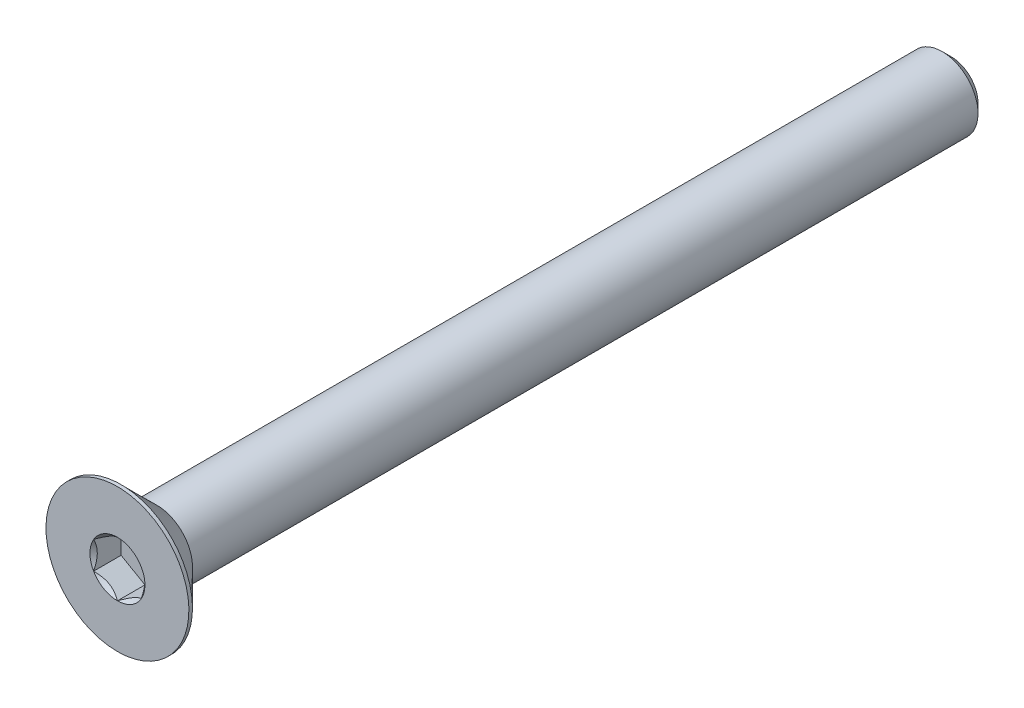
from build123d import *

# Parameters (mm, degrees)
SKETCH1_W          = 70
SKETCH1_H          = 3
CHAMFER1_SIZE      = 0.75
CUT_EXTRUDE2_DEPTH = 2.31


with BuildPart() as part:
    # Sketch1 → Revolve1 (revolve)
    with BuildSketch(Plane(origin=(0, 0, 0), x_dir=(0, 0, -1), z_dir=(1, 0, 0))):
        with Locations((35, 1.5)):
            Rectangle(SKETCH1_W, SKETCH1_H)
    revolve(axis=Axis((0, 0, -70), (0, 0, 1)))

    # Chamfer1
    chamfer1_edges = [part.edges().sort_by_distance(p)[0] for p in [
        (0, -3, -70),
    ]]
    chamfer(chamfer1_edges, length=CHAMFER1_SIZE)

    # Sketch7 → Revolve2 (revolve)
    with BuildSketch(Plane(origin=(0, 0, 0), x_dir=(0, 0, -1), z_dir=(1, 0, 0)), mode=Mode.PRIVATE) as revolve2_sk:
        Polygon((0, 6), (0.3, 6), (3.3, 3), (3.3, 0), (0, 0), align=None)
    revolve(revolve2_sk.sketch.rotate(Axis((0, 0, 0), (0, 0, -1)), 180), axis=Axis((0, 0, 0), (0, 0, -1)))

    # Boss-Extrude1 cone 1 section (through the dimple's axis) → Boss-Extrude1 (revolve)
    with BuildSketch(Plane(origin=(0, 0, -3.3), x_dir=(0, -1, 0), z_dir=(1, 0, 0))):
        Polygon((0, 0), (3, 0), (0, 3), align=None)
    revolve(axis=Axis((0, 0, -3.3), (0, 0, -1)))

    # Sketch5 → Cut-Extrude2 (cut)
    with BuildSketch(Plane.XY):
        Polygon((2, -1.154700538), (2, 1.154700538), (0, 2.309401077), (-2, 1.154700538), (-2, -1.154700538), (0, -2.309401077), align=None)
    extrude(amount=-CUT_EXTRUDE2_DEPTH, mode=Mode.SUBTRACT)

    # Cut-Extrude3 cone 1 section (through the dimple's axis) → Cut-Extrude3 (revolve, cut)
    with BuildSketch(Plane(origin=(0, 0, 0), x_dir=(0, -1, 0), z_dir=(1, 0, 0))):
        Polygon((0, 0), (2.309401077, 0), (0, 2.309401077), align=None)
    revolve(axis=Axis((0, 0, 0), (0, 0, -1)), mode=Mode.SUBTRACT)


solid = part.part
